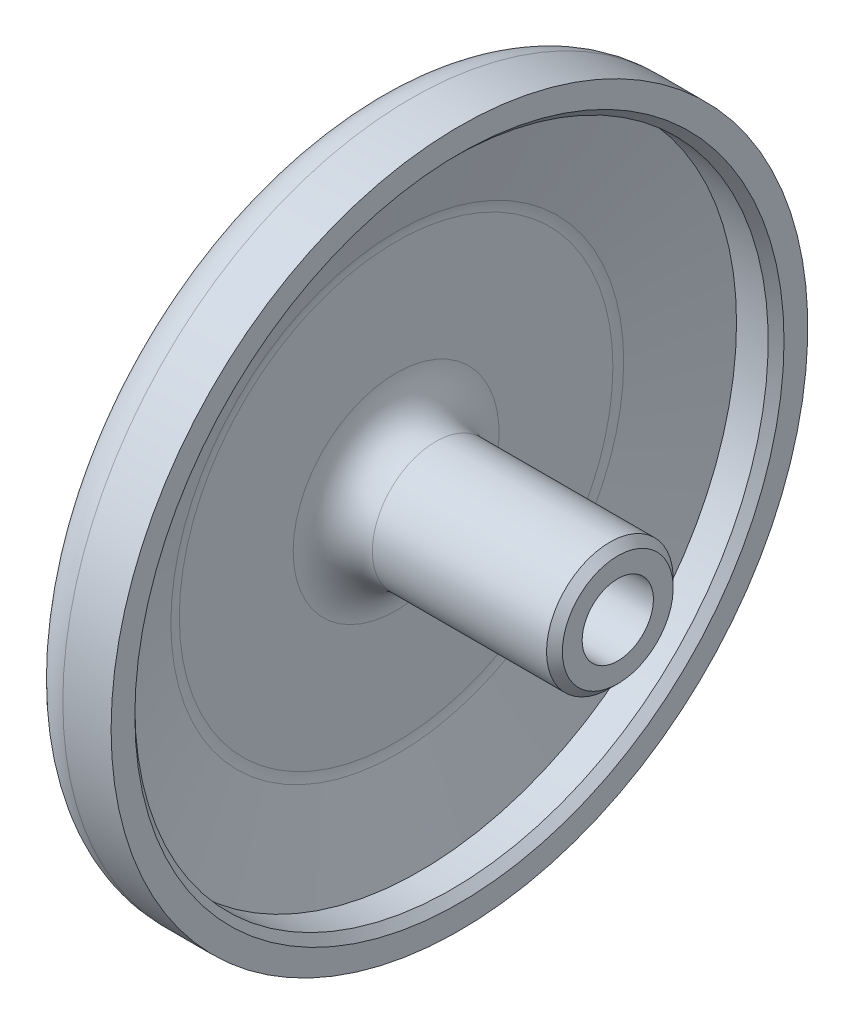
from build123d import *

# Parameters (mm, degrees)
FILLET1_R          = 2.5
CHAMFER1_SIZE      = 0.5
SKETCH3_R          = 2.25
CUT_EXTRUDE1_DEPTH = 18
CHAMFER2_SIZE      = 1


with BuildPart() as part:
    # Sketch1 → Revolve1 (revolve)
    with BuildSketch(Plane.XY):
        Polygon((4, 22), (4, 20), (1.5, 20), (0, 14), (0, 4), (14, 4), (14, 0), (-3, 0), (-3, 14), (-1, 22), align=None)
    revolve(axis=Axis((0, 0, 0), (1, 0, 0)))

    # Fillet1
    fillet1_edges = [part.edges().sort_by_distance(p)[0] for p in [
        (-1, -22, 0),
        (-3, -14, 0),
        (0, -4, 0),
        (0, -14, 0),
    ]]
    fillet(fillet1_edges, radius=FILLET1_R)

    # Chamfer1
    chamfer1_edges = [part.edges().sort_by_distance(p)[0] for p in [
        (4, -20, 0),
        (14, -4, 0),
    ]]
    chamfer(chamfer1_edges, length=CHAMFER1_SIZE)

    # Sketch3 → Cut-Extrude1 (cut, through all)
    with BuildSketch(Plane.ZY.offset(3)):
        Circle(SKETCH3_R)
    extrude(amount=-CUT_EXTRUDE1_DEPTH, mode=Mode.SUBTRACT)

    # Chamfer2
    chamfer2_edges = [part.edges().sort_by_distance(p)[0] for p in [
        (-3, 0, -2.25),
    ]]
    chamfer(chamfer2_edges, length=CHAMFER2_SIZE)


solid = part.part
